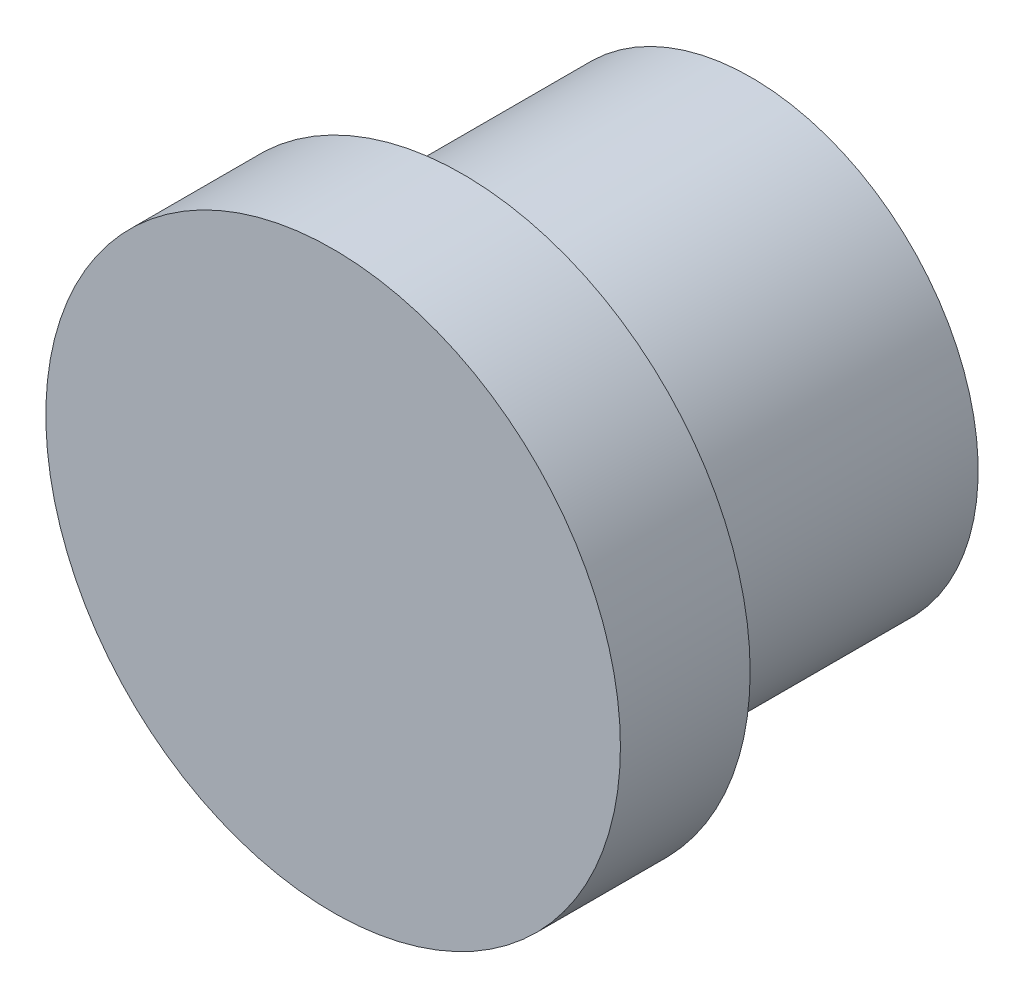
from build123d import *

# Parameters (mm, degrees)
SKETCH1_R           = 9
BOSS_EXTRUDE1_DEPTH = 4.064
SKETCH2_R           = 7.11
BOSS_EXTRUDE2_DEPTH = 9.032941435


with BuildPart() as part:
    # Sketch1 → Boss-Extrude1 (new body)
    with BuildSketch(Plane.XY):
        Circle(SKETCH1_R)
    extrude(amount=BOSS_EXTRUDE1_DEPTH)

    # Sketch2 → Boss-Extrude2 (add)
    with BuildSketch(Plane(origin=(0, 0, 0), x_dir=(-1, 0, 0), z_dir=(0, 0, -1))):
        Circle(SKETCH2_R)
    extrude(amount=BOSS_EXTRUDE2_DEPTH)


solid = part.part
